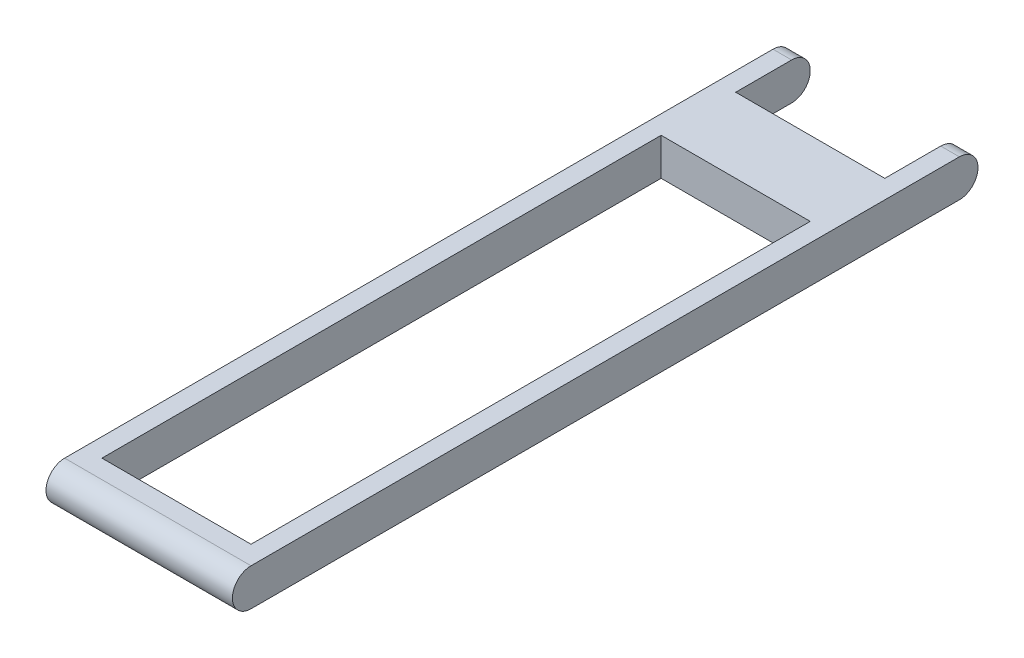
from build123d import *

# Parameters (mm, degrees)
EXTRUDE_1_DEPTH     = 10
SKETCH_3_W          = 8
SKETCH_3_H          = 30
SKETCH_3_H_2        = 7.511837771
CUT_EXTRUDE_2_DEPTH = 10


with BuildPart() as part:
    # 草图1 → 凸台-拉伸1 (new body)
    with BuildSketch(Plane(origin=(0, 0, 0), x_dir=(0, 0, -1), z_dir=(1, 0, 0))):
        with BuildLine():
            Line((-19, 1), (19, 1))
            ThreePointArc((19, 1), (20, 0), (19, -1))
            Line((19, -1), (-19, -1))
            ThreePointArc((-19, -1), (-20, 0), (-19, 1))
        make_face()
    extrude(amount=EXTRUDE_1_DEPTH)

    # 草图3 → 切除-拉伸2 (cut)
    with BuildSketch(Plane(origin=(0, 1, 0), x_dir=(1, 0, 0), z_dir=(0, 1, 0))):
        with Locations((5, -3)):
            Rectangle(SKETCH_3_W, SKETCH_3_H)
        with Locations((5, 19.755918886)):
            Rectangle(SKETCH_3_W, SKETCH_3_H_2)
    extrude(amount=-CUT_EXTRUDE_2_DEPTH, mode=Mode.SUBTRACT)


solid = part.part
